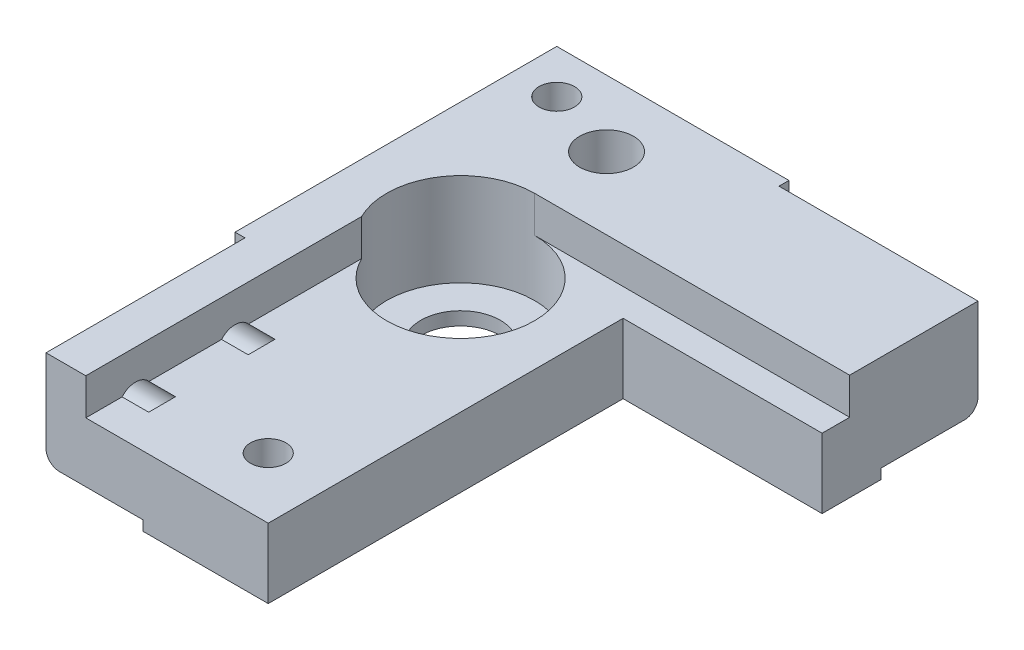
from build123d import *

# Parameters (mm, degrees)
SALIENTE_EXTRUIR1_DEPTH = 16
CROQUIS6_R              = 11.15
CORTAR_EXTRUIR4_DEPTH   = 14
CROQUIS22_R             = 6
CORTAR_EXTRUIR17_DEPTH  = 3
CROQUIS8_R              = 4.05
CORTAR_EXTRUIR6_DEPTH   = 17
CORTAR_EXTRUIR12_DEPTH  = 30
CROQUIS18_R             = 2.675
CORTAR_EXTRUIR13_DEPTH  = 15
CORTAR_EXTRUIR10_DEPTH  = 30
CROQUIS16_R             = 2.675
CORTAR_EXTRUIR11_DEPTH  = 10
CROQUIS19_R             = 2.675
CORTAR_EXTRUIR14_DEPTH  = 17
CORTAR_EXTRUIR19_DEPTH  = 5.5
REDONDEO1_R             = 2


with BuildPart() as part:
    # Croquis2 → Saliente-Extruir1 (new body)
    with BuildSketch(Plane(origin=(0, 0, 0), x_dir=(-1, 0, 0), z_dir=(0, 1, 0))):
        Polygon((0, 0), (-65, 0), (-65, 25), (-35, 25), (-35, 78.5), (0, 78.5), align=None)
    extrude(amount=SALIENTE_EXTRUIR1_DEPTH)

    # Croquis6 → Cortar-Extruir4 (cut)
    with BuildSketch(Plane(origin=(0, 16, 0), x_dir=(-1, 0, 0), z_dir=(0, 1, 0))):
        with Locations((-17.5, 32)):
            Circle(CROQUIS6_R)
    extrude(amount=-CORTAR_EXTRUIR4_DEPTH, mode=Mode.SUBTRACT)

    # Croquis22 → Cortar-Extruir17 (cut, through all)
    with BuildSketch(Plane(origin=(0, 2, 0), x_dir=(1, 0, 0), z_dir=(0, 1, 0))):
        with Locations((17.5, -32)):
            Circle(CROQUIS22_R)
    extrude(amount=-CORTAR_EXTRUIR17_DEPTH, mode=Mode.SUBTRACT)

    # Croquis8 → Cortar-Extruir6 (cut, through all)
    with BuildSketch(Plane(origin=(0, 16, 0), x_dir=(-1, 0, 0), z_dir=(0, 1, 0))):
        with Locations((-17.5, 10)):
            Circle(CROQUIS8_R)
    extrude(amount=-CORTAR_EXTRUIR6_DEPTH, mode=Mode.SUBTRACT)

    # Croquis17 → Cortar-Extruir12 (cut)
    with BuildSketch(Plane(origin=(65, 0, 0), x_dir=(0, 0, -1), z_dir=(1, 0, 0))):
        Polygon((-16.1, 0), (-16.1, 1.5), (-1.5, 1.5), (-1.5, 16.1), (0, 16.1), (0, 0), align=None)
    extrude(amount=-CORTAR_EXTRUIR12_DEPTH, mode=Mode.SUBTRACT)

    # Croquis18 → Cortar-Extruir13 (cut)
    with BuildSketch(Plane(origin=(0, 0, 1.5), x_dir=(-1, 0, 0), z_dir=(0, 0, -1))):
        with Locations((-42.5, 8.75)):
            Circle(CROQUIS18_R)
        with Locations((-57.5, 8.75)):
            Circle(CROQUIS18_R)
    extrude(amount=-CORTAR_EXTRUIR13_DEPTH, mode=Mode.SUBTRACT)

    # Croquis15 → Cortar-Extruir10 (cut)
    with BuildSketch(Plane.XY.offset(78.5)):
        Polygon((0, 0), (0, 16.1), (1.5, 16.1), (1.5, 1.5), (16.1, 1.5), (16.1, 0), align=None)
    extrude(amount=-CORTAR_EXTRUIR10_DEPTH, mode=Mode.SUBTRACT)

    # Croquis16 → Cortar-Extruir11 (cut)
    with BuildSketch(Plane.ZY.offset(-1.5)):
        with Locations((56, 8.75)):
            Circle(CROQUIS16_R)
        with Locations((71, 8.75)):
            Circle(CROQUIS16_R)
    extrude(amount=-CORTAR_EXTRUIR11_DEPTH, mode=Mode.SUBTRACT)

    # Croquis19 → Cortar-Extruir14 (cut, through all)
    with BuildSketch(Plane(origin=(0, 16, 0), x_dir=(1, 0, 0), z_dir=(0, 1, 0))):
        with Locations((6.580936897, -6.580936897)):
            Circle(CROQUIS19_R)
        with Locations((25.84554815, -69.34554815)):
            Circle(CROQUIS19_R)
    extrude(amount=-CORTAR_EXTRUIR14_DEPTH, mode=Mode.SUBTRACT)

    # Croquis23 → Cortar-Extruir19 (cut)
    with BuildSketch(Plane(origin=(0, 16, 0), x_dir=(1, 0, 0), z_dir=(0, 1, 0))):
        with BuildLine():
            Line((35, -78.5), (7.5, -78.5))
            Line((7.5, -78.5), (7.5, -27.068215333))
            ThreePointArc((7.5, -27.068215333), (11.612169289, -22.531317435), (17.5, -20.85))
            Line((17.5, -20.85), (65, -20.85))
            Line((65, -20.85), (65, -25))
            Line((65, -25), (35, -25))
            Line((35, -25), (35, -78.5))
        make_face()
    extrude(amount=-CORTAR_EXTRUIR19_DEPTH, mode=Mode.SUBTRACT)

    # Redondeo1
    redondeo1_edges = [part.edges().sort_by_distance(p)[0] for p in [
        (50, 1.5, 1.5),
        (1.5, 1.5, 63.5),
    ]]
    fillet(redondeo1_edges, radius=REDONDEO1_R)


solid = part.part
